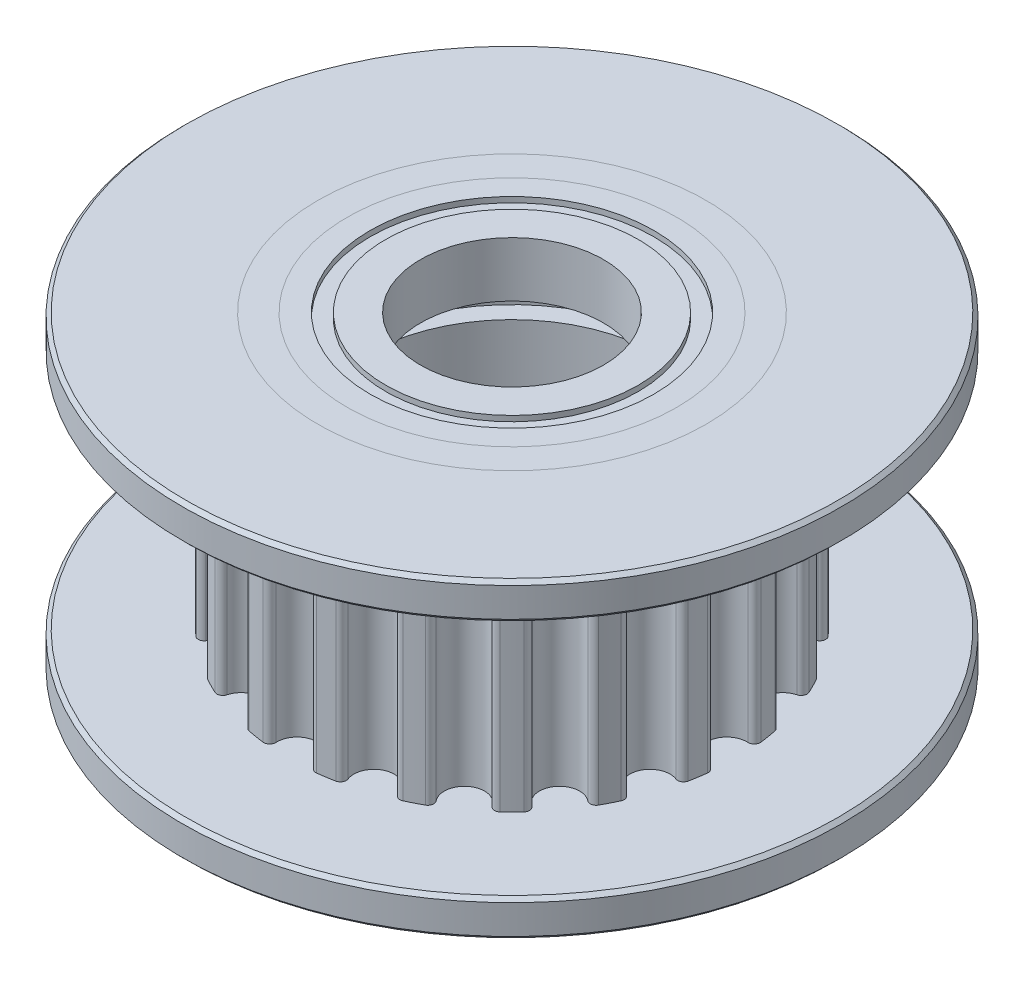
from build123d import *

# Parameters (mm, degrees)
SKICA2_R                 = 9
ODEBRAT_VYSUNUT_M1_DEPTH = 6.5
SKICA3_R                 = 9
SKICA3_R_2               = 5.3
P_IDAT_VYSUNUT_M1_DEPTH  = 1
SKICA5_R                 = 9
SKICA5_R_2               = 5.3
P_IDAT_VYSUNUT_M2_DEPTH  = 1
ZKOSEN_1_SIZE            = 0.1
ZKOSEN_2_SIZE            = 0.1
SKETCH1_R                = 4.5
SKETCH1_R_2              = 2.5
BOSS_EXTRUDE1_DEPTH      = 1.5
SKETCH3_R                = 3.875
SKETCH3_R_2              = 3.45
CUT_EXTRUDE1_DEPTH       = 0.15


with BuildPart() as part:
    # Skica1 → Rotovat1 (revolve)
    with BuildSketch(Plane.XY):
        Polygon((4.5, 8.5), (5.3, 8.5), (5.3, 7.5), (9, 7.5), (9, 1), (5.3, 1), (5.3, 0), (4.5, 0), (4.5, 3), (4, 3), (4, 5.5), (4.5, 5.5), align=None)
    revolve(axis=Axis((0, 0, 0), (0, 1, 0)))

    # Skica2 → Odebrat vysunutím1 (cut)
    with BuildSketch(Plane(origin=(0, 7.5, 0), x_dir=(1, 0, 0), z_dir=(0, 1, 0))):
        Circle(SKICA2_R)
        with BuildLine():
            ThreePointArc((-0.549227949, 5.899131775), (0, 5.32), (0.549227949, 5.899131775))
            ThreePointArc((0.549227949, 5.899131775), (0.599687134, 6.024439536), (0.728068988, 6.06646648))
            ThreePointArc((0.728068988, 6.06646648), (0.955814581, 6.034775761), (1.182206482, 5.994538167))
            ThreePointArc((1.182206482, 5.994538167), (1.291317841, 5.914895994), (1.300585151, 5.780128485))
            ThreePointArc((1.300585151, 5.780128485), (1.64397041, 5.059620667), (2.34527879, 5.440686945))
            ThreePointArc((2.34527879, 5.440686945), (2.431990555, 5.544268962), (2.567075994, 5.544566786))
            ThreePointArc((2.567075994, 5.544566786), (2.773881953, 5.444049863), (2.976759346, 5.335822692))
            ThreePointArc((2.976759346, 5.335822692), (3.05591963, 5.22636122), (3.023087915, 5.095325947))
            ThreePointArc((3.023087915, 5.095325947), (3.127017542, 4.30397041), (3.911757403, 4.44966977))
            ThreePointArc((3.911757403, 4.44966977), (4.026233796, 4.521386713), (4.154799715, 4.479926264))
            ThreePointArc((4.154799715, 4.479926264), (4.320422433, 4.320422433), (4.479926264, 4.154799715))
            ThreePointArc((4.479926264, 4.154799715), (4.521386713, 4.026233796), (4.44966977, 3.911757403))
            ThreePointArc((4.44966977, 3.911757403), (4.30397041, 3.127017542), (5.095325947, 3.023087915))
            ThreePointArc((5.095325947, 3.023087915), (5.22636122, 3.05591963), (5.335822692, 2.976759346))
            ThreePointArc((5.335822692, 2.976759346), (5.444049863, 2.773881953), (5.544566786, 2.567075994))
            ThreePointArc((5.544566786, 2.567075994), (5.544268962, 2.431990555), (5.440686945, 2.34527879))
            ThreePointArc((5.440686945, 2.34527879), (5.059620667, 1.64397041), (5.780128485, 1.300585151))
            ThreePointArc((5.780128485, 1.300585151), (5.914895994, 1.291317841), (5.994538167, 1.182206482))
            ThreePointArc((5.994538167, 1.182206482), (6.034775761, 0.955814581), (6.06646648, 0.728068988))
            ThreePointArc((6.06646648, 0.728068988), (6.024439536, 0.599687134), (5.899131775, 0.549227949))
            ThreePointArc((5.899131775, 0.549227949), (5.32, 0), (5.899131775, -0.549227949))
            ThreePointArc((5.899131775, -0.549227949), (6.024439536, -0.599687134), (6.06646648, -0.728068988))
            ThreePointArc((6.06646648, -0.728068988), (6.034775761, -0.955814581), (5.994538167, -1.182206482))
            ThreePointArc((5.994538167, -1.182206482), (5.914895994, -1.291317841), (5.780128485, -1.300585151))
            ThreePointArc((5.780128485, -1.300585151), (5.059620667, -1.64397041), (5.440686945, -2.34527879))
            ThreePointArc((5.440686945, -2.34527879), (5.544268962, -2.431990555), (5.544566786, -2.567075994))
            ThreePointArc((5.544566786, -2.567075994), (5.444049863, -2.773881953), (5.335822692, -2.976759346))
            ThreePointArc((5.335822692, -2.976759346), (5.22636122, -3.05591963), (5.095325947, -3.023087915))
            ThreePointArc((5.095325947, -3.023087915), (4.30397041, -3.127017542), (4.44966977, -3.911757403))
            ThreePointArc((4.44966977, -3.911757403), (4.521386713, -4.026233796), (4.479926264, -4.154799715))
            ThreePointArc((4.479926264, -4.154799715), (4.320422433, -4.320422433), (4.154799715, -4.479926264))
            ThreePointArc((4.154799715, -4.479926264), (4.026233796, -4.521386713), (3.911757403, -4.44966977))
            ThreePointArc((3.911757403, -4.44966977), (3.127017542, -4.30397041), (3.023087915, -5.095325947))
            ThreePointArc((3.023087915, -5.095325947), (3.05591963, -5.22636122), (2.976759346, -5.335822692))
            ThreePointArc((2.976759346, -5.335822692), (2.773881953, -5.444049863), (2.567075994, -5.544566786))
            ThreePointArc((2.567075994, -5.544566786), (2.431990555, -5.544268962), (2.34527879, -5.440686945))
            ThreePointArc((2.34527879, -5.440686945), (1.64397041, -5.059620667), (1.300585151, -5.780128485))
            ThreePointArc((1.300585151, -5.780128485), (1.291317841, -5.914895994), (1.182206482, -5.994538167))
            ThreePointArc((1.182206482, -5.994538167), (0.955814581, -6.034775761), (0.728068988, -6.06646648))
            ThreePointArc((0.728068988, -6.06646648), (0.599687134, -6.024439536), (0.549227949, -5.899131775))
            ThreePointArc((0.549227949, -5.899131775), (0, -5.32), (-0.549227949, -5.899131775))
            ThreePointArc((-0.549227949, -5.899131775), (-0.599687134, -6.024439536), (-0.728068988, -6.06646648))
            ThreePointArc((-0.728068988, -6.06646648), (-0.955814581, -6.034775761), (-1.182206482, -5.994538167))
            ThreePointArc((-1.182206482, -5.994538167), (-1.291317841, -5.914895994), (-1.300585151, -5.780128485))
            ThreePointArc((-1.300585151, -5.780128485), (-1.64397041, -5.059620667), (-2.34527879, -5.440686945))
            ThreePointArc((-2.34527879, -5.440686945), (-2.431990555, -5.544268962), (-2.567075994, -5.544566786))
            ThreePointArc((-2.567075994, -5.544566786), (-2.773881953, -5.444049863), (-2.976759346, -5.335822692))
            ThreePointArc((-2.976759346, -5.335822692), (-3.05591963, -5.22636122), (-3.023087915, -5.095325947))
            ThreePointArc((-3.023087915, -5.095325947), (-3.127017542, -4.30397041), (-3.911757403, -4.44966977))
            ThreePointArc((-3.911757403, -4.44966977), (-4.026233796, -4.521386713), (-4.154799715, -4.479926264))
            ThreePointArc((-4.154799715, -4.479926264), (-4.320422433, -4.320422433), (-4.479926264, -4.154799715))
            ThreePointArc((-4.479926264, -4.154799715), (-4.521386713, -4.026233796), (-4.44966977, -3.911757403))
            ThreePointArc((-4.44966977, -3.911757403), (-4.30397041, -3.127017542), (-5.095325947, -3.023087915))
            ThreePointArc((-5.095325947, -3.023087915), (-5.22636122, -3.05591963), (-5.335822692, -2.976759346))
            ThreePointArc((-5.335822692, -2.976759346), (-5.444049863, -2.773881953), (-5.544566786, -2.567075994))
            ThreePointArc((-5.544566786, -2.567075994), (-5.544268962, -2.431990555), (-5.440686945, -2.34527879))
            ThreePointArc((-5.440686945, -2.34527879), (-5.059620667, -1.64397041), (-5.780128485, -1.300585151))
            ThreePointArc((-5.780128485, -1.300585151), (-5.914895994, -1.291317841), (-5.994538167, -1.182206482))
            ThreePointArc((-5.994538167, -1.182206482), (-6.034775761, -0.955814581), (-6.06646648, -0.728068988))
            ThreePointArc((-6.06646648, -0.728068988), (-6.024439536, -0.599687134), (-5.899131775, -0.549227949))
            ThreePointArc((-5.899131775, -0.549227949), (-5.32, 0), (-5.899131775, 0.549227949))
            ThreePointArc((-5.899131775, 0.549227949), (-6.024439536, 0.599687134), (-6.06646648, 0.728068988))
            ThreePointArc((-6.06646648, 0.728068988), (-6.034775761, 0.955814581), (-5.994538167, 1.182206482))
            ThreePointArc((-5.994538167, 1.182206482), (-5.914895994, 1.291317841), (-5.780128485, 1.300585151))
            ThreePointArc((-5.780128485, 1.300585151), (-5.059620667, 1.64397041), (-5.440686945, 2.34527879))
            ThreePointArc((-5.440686945, 2.34527879), (-5.544268962, 2.431990555), (-5.544566786, 2.567075994))
            ThreePointArc((-5.544566786, 2.567075994), (-5.444049863, 2.773881953), (-5.335822692, 2.976759346))
            ThreePointArc((-5.335822692, 2.976759346), (-5.22636122, 3.05591963), (-5.095325947, 3.023087915))
            ThreePointArc((-5.095325947, 3.023087915), (-4.30397041, 3.127017542), (-4.44966977, 3.911757403))
            ThreePointArc((-4.44966977, 3.911757403), (-4.521386713, 4.026233796), (-4.479926264, 4.154799715))
            ThreePointArc((-4.479926264, 4.154799715), (-4.320422433, 4.320422433), (-4.154799715, 4.479926264))
            ThreePointArc((-4.154799715, 4.479926264), (-4.026233796, 4.521386713), (-3.911757403, 4.44966977))
            ThreePointArc((-3.911757403, 4.44966977), (-3.127017542, 4.30397041), (-3.023087915, 5.095325947))
            ThreePointArc((-3.023087915, 5.095325947), (-3.05591963, 5.22636122), (-2.976759346, 5.335822692))
            ThreePointArc((-2.976759346, 5.335822692), (-2.773881953, 5.444049863), (-2.567075994, 5.544566786))
            ThreePointArc((-2.567075994, 5.544566786), (-2.431990555, 5.544268962), (-2.34527879, 5.440686945))
            ThreePointArc((-2.34527879, 5.440686945), (-1.64397041, 5.059620667), (-1.300585151, 5.780128485))
            ThreePointArc((-1.300585151, 5.780128485), (-1.291317841, 5.914895994), (-1.182206482, 5.994538167))
            ThreePointArc((-1.182206482, 5.994538167), (-0.955814581, 6.034775761), (-0.728068988, 6.06646648))
            ThreePointArc((-0.728068988, 6.06646648), (-0.599687134, 6.024439536), (-0.549227949, 5.899131775))
        make_face(mode=Mode.SUBTRACT)
    extrude(amount=-ODEBRAT_VYSUNUT_M1_DEPTH, mode=Mode.SUBTRACT)


with BuildPart() as body_2:
    # Skica3 → Přidat vysunutím1 (new body)
    with BuildSketch(Plane(origin=(0, 7.5, 0), x_dir=(1, 0, 0), z_dir=(0, 1, 0))):
        with Locations(Location((0, 0, 0), (0, 0, 180))):  # turned: the seam where the file's is
            Circle(SKICA3_R)
        with Locations(Location((0, 0, 0), (0, 0, 180))):  # turned: the seam where the file's is
            Circle(SKICA3_R_2, mode=Mode.SUBTRACT)
    extrude(amount=P_IDAT_VYSUNUT_M1_DEPTH)

    # Zkosení1
    zkosen_1_edges = [body_2.edges().sort_by_distance(p)[0] for p in [
        (9, 7.5, 0),
        (9, 8.5, 0),
    ]]
    chamfer(zkosen_1_edges, length=ZKOSEN_1_SIZE)


with BuildPart() as body_3:
    # Skica5 → Přidat vysunutím2 (new body)
    with BuildSketch(Plane.XZ.offset(-1)):
        Circle(SKICA5_R)
        Circle(SKICA5_R_2, mode=Mode.SUBTRACT)
    extrude(amount=P_IDAT_VYSUNUT_M2_DEPTH)

    # Zkosení2
    zkosen_2_edges = [body_3.edges().sort_by_distance(p)[0] for p in [
        (-9, 1, 0),
        (-9, 0, 0),
    ]]
    chamfer(zkosen_2_edges, length=ZKOSEN_2_SIZE)


with BuildPart() as body_4:
    # Sketch1 → Boss-Extrude1 (new body)
    with BuildSketch(Plane.XZ):
        Circle(SKETCH1_R)
        Circle(SKETCH1_R_2, mode=Mode.SUBTRACT)
    extrude(amount=-BOSS_EXTRUDE1_DEPTH)

    # Sketch3 → Cut-Extrude1 (cut)
    with BuildSketch(Plane.XZ):
        Circle(SKETCH3_R)
        Circle(SKETCH3_R_2, mode=Mode.SUBTRACT)
    extrude(amount=-CUT_EXTRUDE1_DEPTH, mode=Mode.SUBTRACT)


with BuildPart() as body_5:
    # Mirror3: mirrored copy
    add(body_4.part.mirror(Plane.ZX.offset(4.25)))


solid = Compound([part.part, body_2.part, body_3.part, body_4.part, body_5.part])
